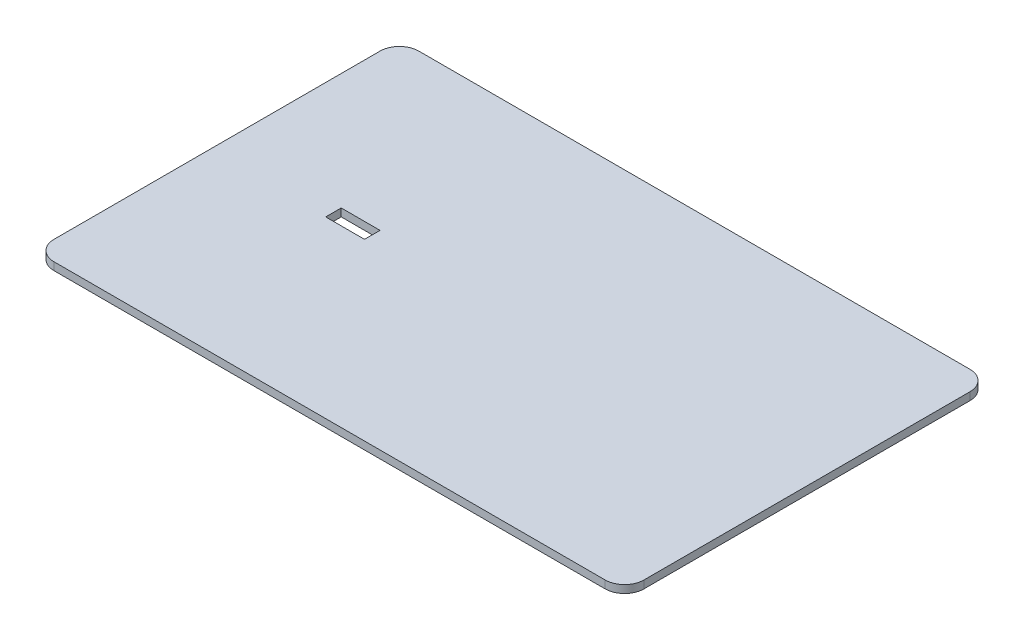
from build123d import *

# Parameters (mm, degrees)
SKETCH1_W           = 76
SKETCH1_H           = 47
BOSS_EXTRUDE1_DEPTH = 1
SKETCH2_W           = 66
SKETCH2_H           = 41
SKETCH2_W_2         = 61
SKETCH2_H_2         = 36
BOSS_EXTRUDE2_DEPTH = 2.5
FILLET1_R           = 2.5
SKETCH4_W           = 5
SKETCH4_H           = 2
CUT_EXTRUDE1_DEPTH  = 1


with BuildPart() as part:
    # Sketch1 → Boss-Extrude1 (new body)
    with BuildSketch(Plane(origin=(0, 0, 0), x_dir=(1, 0, 0), z_dir=(0, 1, 0))):
        Rectangle(SKETCH1_W, SKETCH1_H)
    extrude(amount=-BOSS_EXTRUDE1_DEPTH)

    # Sketch2 → Boss-Extrude2 (add)
    with BuildSketch(Plane.XZ.offset(1)):
        Rectangle(SKETCH2_W, SKETCH2_H)
        Rectangle(SKETCH2_W_2, SKETCH2_H_2, mode=Mode.SUBTRACT)
    extrude(amount=BOSS_EXTRUDE2_DEPTH)

    # Fillet1
    fillet1_edges = [part.edges().sort_by_distance(p)[0] for p in [
        (38, -0.5, 23.5),
        (-38, -0.5, 23.5),
        (-38, -0.5, -23.5),
        (38, -0.5, -23.5),
    ]]
    fillet(fillet1_edges, radius=FILLET1_R)

    # Sketch4 → Cut-Extrude1 (cut)
    with BuildSketch(Plane(origin=(0, 0, 0), x_dir=(1, 0, 0), z_dir=(0, 1, 0))):
        with Locations((-20.5, 0)):
            Rectangle(SKETCH4_W, SKETCH4_H)
    extrude(amount=-CUT_EXTRUDE1_DEPTH, mode=Mode.SUBTRACT)


solid = part.part
